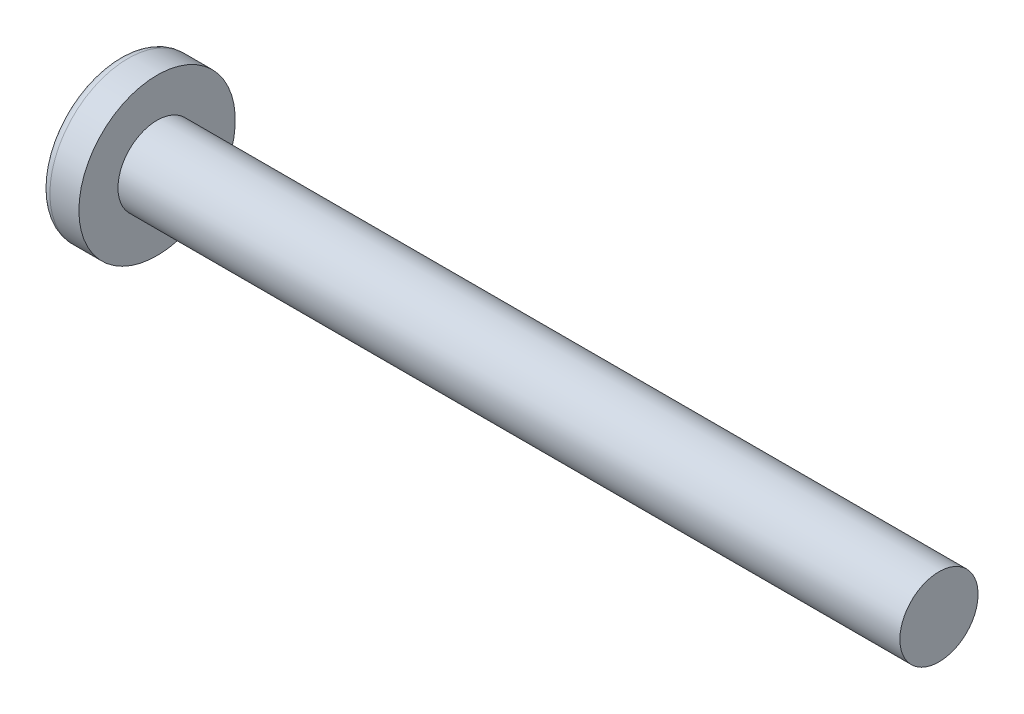
from build123d import *

# Parameters (mm, degrees)
SKETCH3_W         = 0.93
SKETCH3_H         = 4.4
SKETCH4_W         = 0.465
SKETCH4_H         = 0.465
CIRPATTERN1_COUNT = 2
CIRPATTERN1_ANGLE = 90


with BuildPart() as part:
    # BodySke → Base-Revolve (revolve)
    with BuildSketch(Plane.XY):
        with BuildLine():
            Line((3.1, 2), (3.1, 4))
            Line((3.1, 4), (1.616353821, 4))
            ThreePointArc((1.616353821, 4), (1.397629036, 3.947269784), (1.226960106, 3.800664452))
            ThreePointArc((1.226960106, 3.800664452), (0.314340807, 1.996902688), (0, 0))
            Line((0, 0), (43.1, 0))
            Line((43.1, 0), (43.1, 2))
            Line((43.1, 2), (3.1, 2))
        make_face()
    revolve(axis=Axis((-25.4, 0, 0), (1, 0, 0)))

    # Sketch3 → Cut-Loft1 section 0
    with BuildSketch(Plane(origin=(0, 0, 0), x_dir=(0, 0, -1), z_dir=(1, 0, 0))):
        Rectangle(SKETCH3_W, SKETCH3_H)
    # Sketch4 → Cut-Loft1 section 1
    with BuildSketch(Plane(origin=(2.45, 0, 0), x_dir=(0, 0, -1), z_dir=(1, 0, 0))):
        Rectangle(SKETCH4_W, SKETCH4_H)
    cut_loft1 = loft(mode=Mode.SUBTRACT)

    # CirPattern1: Cut-Loft1 ×2 about axis
    cirpattern1_axis = Axis((0, 0, 0), (1, 0, 0))
    for i in range(1, CIRPATTERN1_COUNT):
        add(cut_loft1.rotate(cirpattern1_axis, i * CIRPATTERN1_ANGLE / (CIRPATTERN1_COUNT - 1)), mode=Mode.SUBTRACT)


solid = part.part
